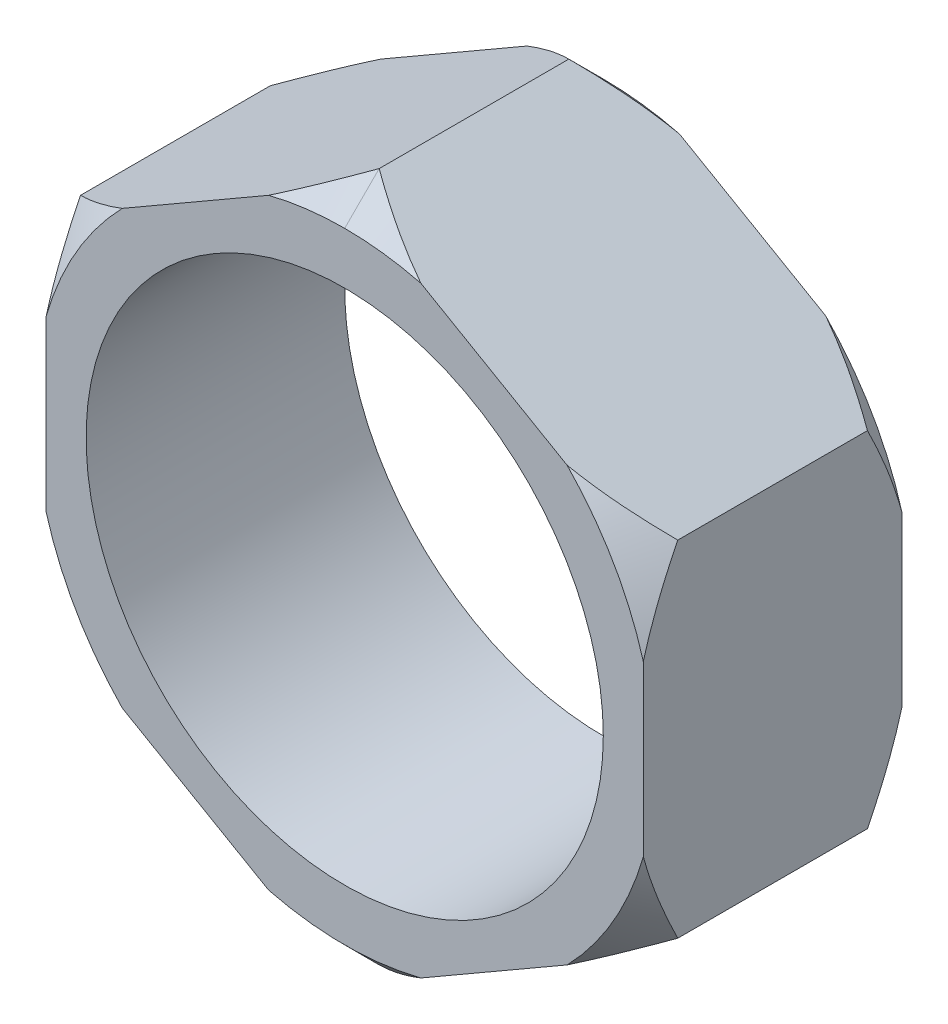
from build123d import *

# Parameters (mm, degrees)
EXTRUDE_1_DEPTH     = 1.5
SKETCH_3_R          = 1.5
CUT_EXTRUDE_1_DEPTH = 1.5


with BuildPart() as part:
    # 草图2 → 凸台-拉伸1 (new body)
    with BuildSketch(Plane.XY):
        Polygon((-1.732050808, 1), (-1.732050808, -1), (0, -2), (1.732050808, -1), (1.732050808, 1), (0, 2), align=None)
    extrude(amount=EXTRUDE_1_DEPTH)

    # 草图3 → 切除-拉伸1 (cut)
    with BuildSketch(Plane.XY.offset(1.5)):
        Circle(SKETCH_3_R)
    extrude(amount=-CUT_EXTRUDE_1_DEPTH, mode=Mode.SUBTRACT)

    # 切除-扫描4: sweep along a path in 草图4
    with BuildLine(Plane(origin=(0, 0, 0), x_dir=(-1, 0, 0), z_dir=(0, 0, -1))) as sweep_4_path:
        CenterArc((0, 0), 1.8, 0, 360)
    # 草图5 → 切除-扫描4 (sweep, cut)
    with BuildSketch(Plane(origin=(0, 0, 0), x_dir=(0, 0, -1), z_dir=(1, 0, 0))):
        Polygon((0, 2), (-0.2, 2), (0, 1.8), align=None)
        Polygon((-1.5, 2), (-1.3, 2), (-1.5, 1.8), align=None)
    sweep(path=sweep_4_path.line, mode=Mode.SUBTRACT)


solid = part.part
